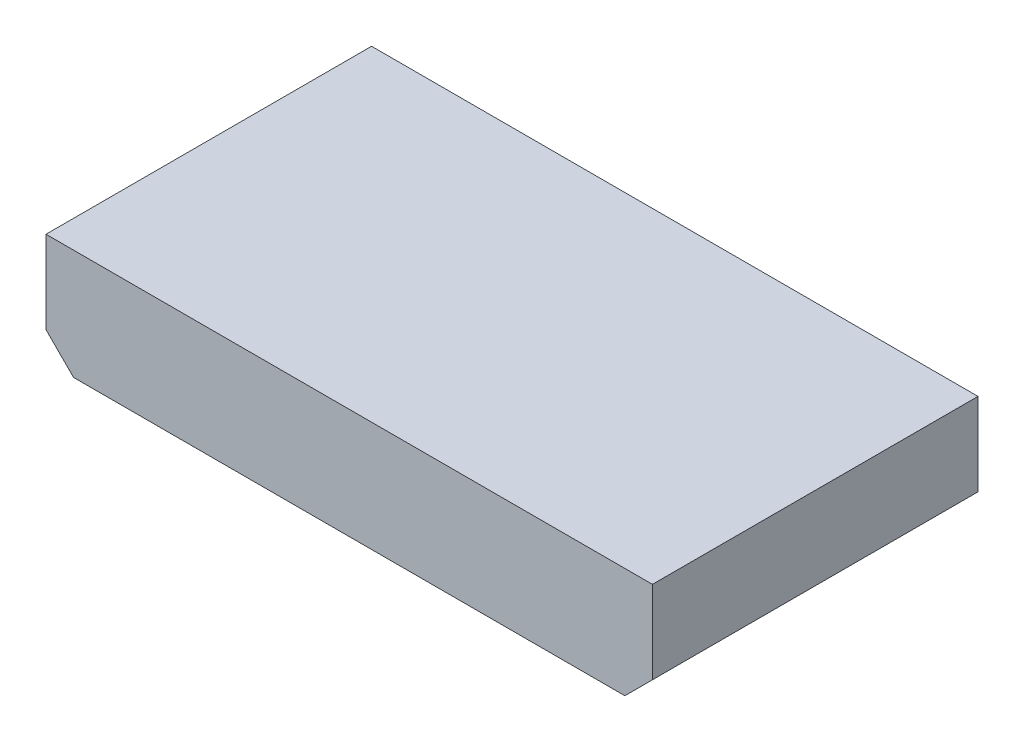
from build123d import *

# Parameters (mm, degrees)
COMPONENT_OUTLINE_DEPTH = 15
SKETCH2_R               = 0.25
EXTRUDE_1_DEPTH         = 2
SKETCH3_R               = 0.25
EXTRUDE_2_DEPTH         = 2
SKETCH4_R               = 0.25
EXTRUDE_3_DEPTH         = 2
SKETCH5_R               = 0.25
EXTRUDE_4_DEPTH         = 2
SKETCH6_R               = 0.25
EXTRUDE_5_DEPTH         = 2
SKETCH7_R               = 0.25
EXTRUDE_6_DEPTH         = 2
SKETCH8_R               = 0.25
EXTRUDE_7_DEPTH         = 2
SKETCH9_R               = 0.25
EXTRUDE_8_DEPTH         = 2


with BuildPart() as part:
    # Sketch1 → Component_Outline (new body)
    with BuildSketch(Plane.XY):
        Polygon((-5.08, 2.54), (-5.08, -1.27), (-3.81, -2.54), (21.59, -2.54), (22.86, -1.27), (22.86, 2.54), align=None)
    extrude(amount=COMPONENT_OUTLINE_DEPTH)


with BuildPart() as body_2:
    # Sketch2 → Extrude 1 (new body)
    with BuildSketch(Plane.XY):
        Circle(SKETCH2_R)
    extrude(amount=-EXTRUDE_1_DEPTH)


with BuildPart() as body_3:
    # Sketch3 → Extrude 2 (new body)
    with BuildSketch(Plane.XY):
        with Locations((2.54, 0)):
            Circle(SKETCH3_R)
    extrude(amount=-EXTRUDE_2_DEPTH)


with BuildPart() as body_4:
    # Sketch4 → Extrude 3 (new body)
    with BuildSketch(Plane.XY):
        with Locations((5.08, 0)):
            Circle(SKETCH4_R)
    extrude(amount=-EXTRUDE_3_DEPTH)


with BuildPart() as body_5:
    # Sketch5 → Extrude 4 (new body)
    with BuildSketch(Plane.XY):
        with Locations((7.62, 0)):
            Circle(SKETCH5_R)
    extrude(amount=-EXTRUDE_4_DEPTH)


with BuildPart() as body_6:
    # Sketch6 → Extrude 5 (new body)
    with BuildSketch(Plane.XY):
        with Locations((10.16, 0)):
            Circle(SKETCH6_R)
    extrude(amount=-EXTRUDE_5_DEPTH)


with BuildPart() as body_7:
    # Sketch7 → Extrude 6 (new body)
    with BuildSketch(Plane.XY):
        with Locations((12.7, 0)):
            Circle(SKETCH7_R)
    extrude(amount=-EXTRUDE_6_DEPTH)


with BuildPart() as body_8:
    # Sketch8 → Extrude 7 (new body)
    with BuildSketch(Plane.XY):
        with Locations((15.24, 0)):
            Circle(SKETCH8_R)
    extrude(amount=-EXTRUDE_7_DEPTH)


with BuildPart() as body_9:
    # Sketch9 → Extrude 8 (new body)
    with BuildSketch(Plane.XY):
        with Locations((17.78, 0)):
            Circle(SKETCH9_R)
    extrude(amount=-EXTRUDE_8_DEPTH)


solid = Compound([part.part, body_2.part, body_3.part, body_4.part, body_5.part, body_6.part, body_7.part, body_8.part, body_9.part])
